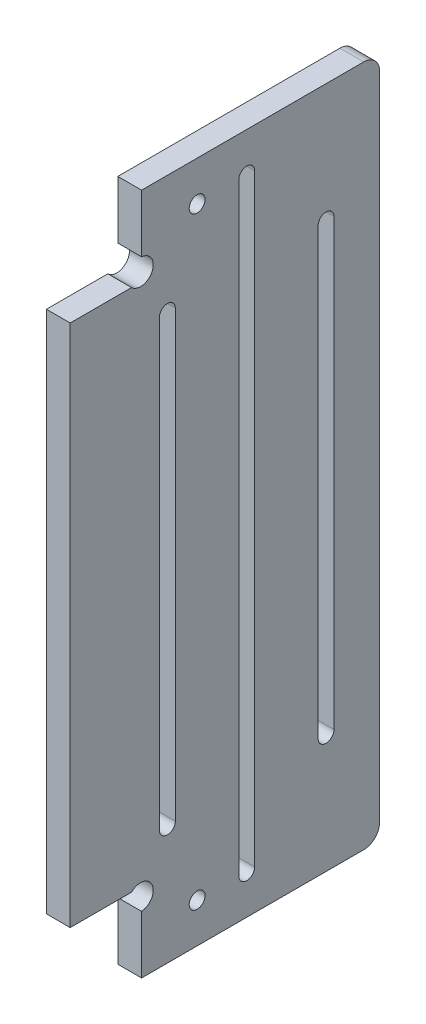
from build123d import *

# Parameters (mm, degrees)
EXTRUSION1_DEPTH        = 3
ENL_V_MAT_EXTRU_2_DEPTH = 4
ESQUISSE4_R             = 1
ENL_V_MAT_EXTRU_3_DEPTH = 4
CONG_1_R                = 2


with BuildPart() as part:
    # Esquisse1 → Extrusion1 (new body)
    with BuildSketch(Plane(origin=(0, 0, 0), x_dir=(0, 0, -1), z_dir=(1, 0, 0))):
        with BuildLine():
            Line((109, 226.862827305), (79, 226.862827305))
            Line((79, 226.862827305), (79, 219.588795816))
            ThreePointArc((79, 219.588795816), (80.320430128, 217.321685018), (77.7372583, 216.862827305))
            Line((77.7372583, 216.862827305), (70, 216.862827305))
            Line((70, 216.862827305), (70, 150.862827305))
            Line((70, 150.862827305), (77.7372583, 150.862827305))
            ThreePointArc((77.7372583, 150.862827305), (80.320430128, 150.403969592), (79, 148.136858794))
            Line((79, 148.136858794), (79, 140.862827305))
            Line((79, 140.862827305), (109, 140.862827305))
            Line((109, 140.862827305), (109, 226.862827305))
        make_face()
    extrude(amount=EXTRUSION1_DEPTH)

    # Esquisse3 → Enlèv. mat.-Extru.2 (cut, through all)
    with BuildSketch(Plane.ZY):
        with BuildLine():
            Line((-83.25, 155.862827305), (-83.25, 211.862827305))
            ThreePointArc((-83.25, 211.862827305), (-82.25, 212.862827305), (-81.25, 211.862827305))
            Line((-81.25, 211.862827305), (-81.25, 155.862827305))
            ThreePointArc((-81.25, 155.862827305), (-82.25, 154.862827305), (-83.25, 155.862827305))
        make_face()
        with BuildLine():
            Line((-93.25, 145.862827305), (-93.25, 221.862827305))
            ThreePointArc((-93.25, 221.862827305), (-92.25, 222.862827305), (-91.25, 221.862827305))
            Line((-91.25, 221.862827305), (-91.25, 145.862827305))
            ThreePointArc((-91.25, 145.862827305), (-92.25, 144.862827305), (-93.25, 145.862827305))
        make_face()
        with BuildLine():
            Line((-103.25, 155.862827305), (-103.25, 211.862827305))
            ThreePointArc((-103.25, 211.862827305), (-102.25, 212.862827305), (-101.25, 211.862827305))
            Line((-101.25, 211.862827305), (-101.25, 155.862827305))
            ThreePointArc((-101.25, 155.862827305), (-102.25, 154.862827305), (-103.25, 155.862827305))
        make_face()
    extrude(amount=-ENL_V_MAT_EXTRU_2_DEPTH, mode=Mode.SUBTRACT)

    # Esquisse4 → Enlèv. mat.-Extru.3 (cut, through all)
    with BuildSketch(Plane.ZY):
        with Locations((-86, 221.862827305)):
            Circle(ESQUISSE4_R)
        with Locations((-86, 145.862827305)):
            Circle(ESQUISSE4_R)
    extrude(amount=-ENL_V_MAT_EXTRU_3_DEPTH, mode=Mode.SUBTRACT)

    # Congé1
    cong_1_edges = [part.edges().sort_by_distance(p)[0] for p in [
        (1.5, 226.862827305, -109),
        (1.5, 140.862827305, -109),
    ]]
    fillet(cong_1_edges, radius=CONG_1_R)


solid = part.part
